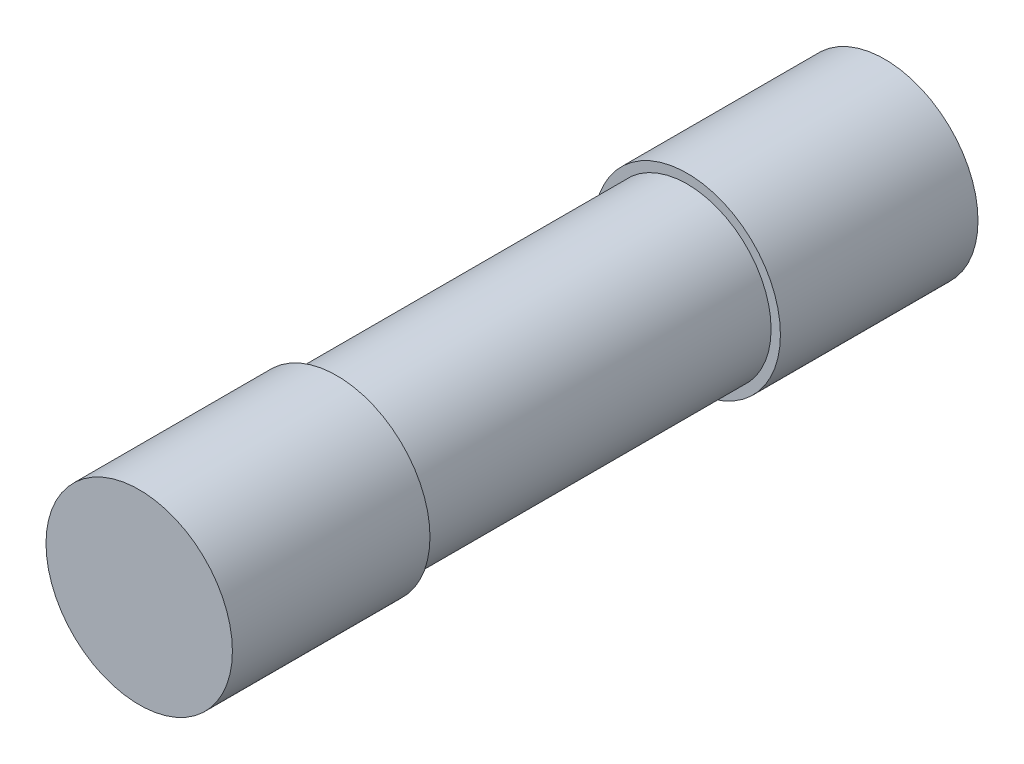
from build123d import *

# Parameters (mm, degrees)
SKETCH1_R           = 2.25
BOSS_EXTRUDE1_DEPTH = 20
SKETCH2_R           = 2.5
BOSS_EXTRUDE2_DEPTH = 5.3
BOSS_EXTRUDE3_START = -14.7
SKETCH2_2_R         = 2.5
BOSS_EXTRUDE3_DEPTH = 5.3


with BuildPart() as part:
    # Sketch1 → Boss-Extrude1 (new body)
    with BuildSketch(Plane.XY):
        Circle(SKETCH1_R)
    extrude(amount=BOSS_EXTRUDE1_DEPTH)

    # Sketch2 → Boss-Extrude2 (add)
    with BuildSketch(Plane(origin=(0, 0, 0), x_dir=(-1, 0, 0), z_dir=(0, 0, -1))):
        Circle(SKETCH2_R)
    extrude(amount=-BOSS_EXTRUDE2_DEPTH)

    # Sketch2_2 → Boss-Extrude3 (add)
    with BuildSketch(Plane(origin=(0, 0, 0), x_dir=(-1, 0, 0), z_dir=(0, 0, -1)).offset(BOSS_EXTRUDE3_START)):
        Circle(SKETCH2_2_R)
    extrude(amount=-BOSS_EXTRUDE3_DEPTH)


solid = part.part
